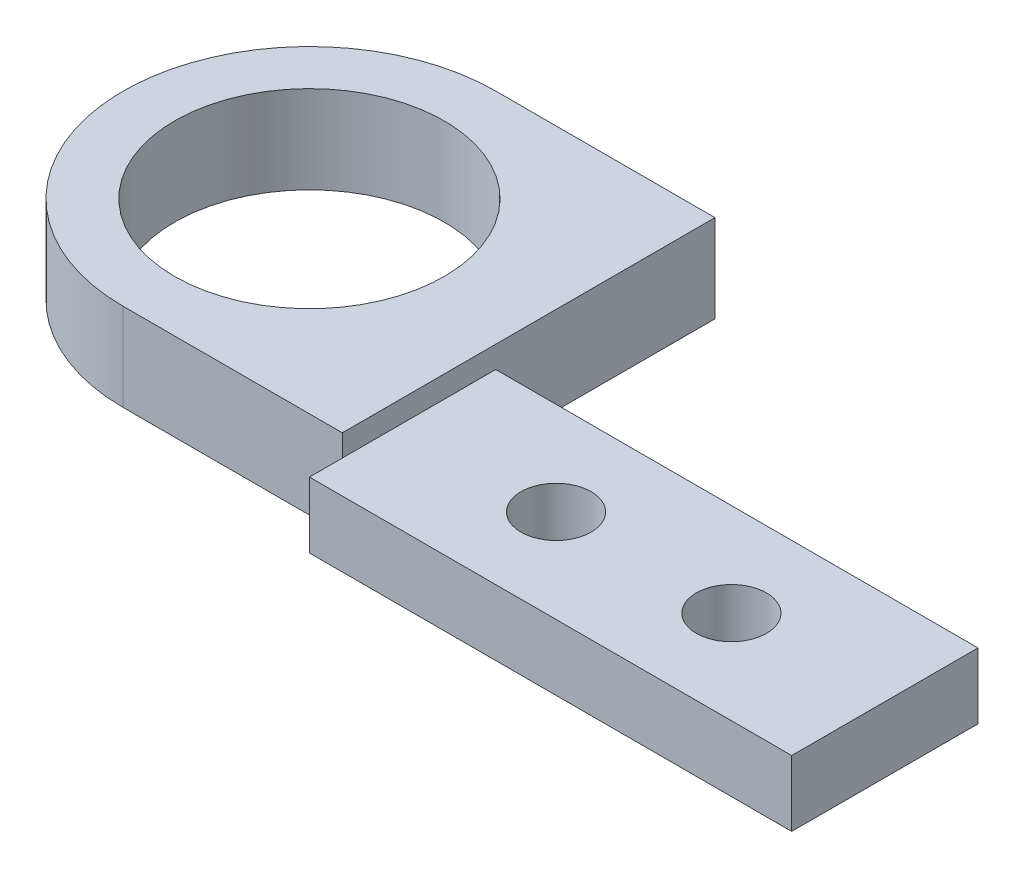
from build123d import *

# Parameters (mm, degrees)
SKETCH1_R           = 6.15
BOSS_EXTRUDE2_DEPTH = 4
SKETCH4_W           = 22
SKETCH4_H           = 8.5
CUT_EXTRUDE2_DEPTH  = 1
SKETCH5_R           = 1.6
CUT_EXTRUDE3_DEPTH  = 5


with BuildPart() as part:
    # Sketch1 → Boss-Extrude2 (new body)
    with BuildSketch(Plane(origin=(0, 0, 0), x_dir=(1, 0, 0), z_dir=(0, 1, 0))):
        with BuildLine():
            Line((10, -1.5), (32, -1.5))
            Line((32, -1.5), (32, -8.5))
            Line((32, -8.5), (32, -10))
            Line((32, -10), (10, -10))
            Line((10, -10), (10, -8.5))
            Line((10, -8.5), (0, -8.5))
            ThreePointArc((0, -8.5), (-8.5, 0), (0, 8.5))
            Line((0, 8.5), (10, 8.5))
            Line((10, 8.5), (10, -1.5))
        make_face()
        Circle(SKETCH1_R, mode=Mode.SUBTRACT)
    extrude(amount=BOSS_EXTRUDE2_DEPTH)

    # Sketch4 → Cut-Extrude2 (cut)
    with BuildSketch(Plane(origin=(0, 4, 0), x_dir=(1, 0, 0), z_dir=(0, 1, 0))):
        with Locations((21, -5.75)):
            Rectangle(SKETCH4_W, SKETCH4_H)
    extrude(amount=-CUT_EXTRUDE2_DEPTH, mode=Mode.SUBTRACT)

    # Sketch5 → Cut-Extrude3 (cut, through all)
    with BuildSketch(Plane.XZ):
        with Locations((17, 5.75)):
            Circle(SKETCH5_R)
        with Locations((25, 5.75)):
            Circle(SKETCH5_R)
    extrude(amount=-CUT_EXTRUDE3_DEPTH, mode=Mode.SUBTRACT)


solid = part.part
